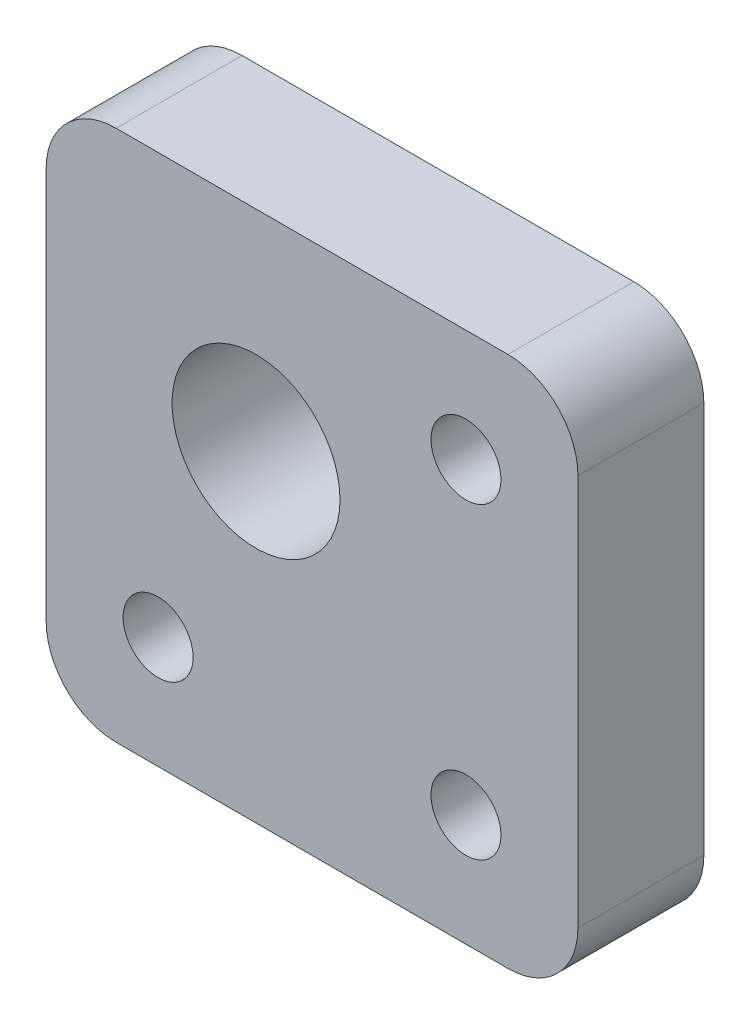
from build123d import *

# Parameters (mm, degrees)
SKETCH_1_W      = 38
SKETCH_1_H      = 38
SKETCH_1_R      = 2.5
SKETCH_1_R_2    = 6
EXTRUDE_1_DEPTH = 9
FILLET_1_R      = 5


with BuildPart() as part:
    # 草图1 → 凸台-拉伸1 (new body)
    with BuildSketch(Plane.XY):
        with Locations((-2.169799589, 0.839779006)):
            Rectangle(SKETCH_1_W, SKETCH_1_H)
        with Locations((8.830200411, 11.839779006)):
            Circle(SKETCH_1_R, mode=Mode.SUBTRACT)
        with Locations((8.830200411, -10.160220994)):
            Circle(SKETCH_1_R, mode=Mode.SUBTRACT)
        with Locations((-13.169799589, -10.160220994)):
            Circle(SKETCH_1_R, mode=Mode.SUBTRACT)
        with Locations((-6.169799589, 4.839779006)):
            Circle(SKETCH_1_R_2, mode=Mode.SUBTRACT)
    extrude(amount=EXTRUDE_1_DEPTH)

    # 圆角1
    fillet_1_edges = [part.edges().sort_by_distance(p)[0] for p in [
        (-21.169799589, 19.839779006, 4.5),
        (16.830200411, 19.839779006, 4.5),
        (16.830200411, -18.160220994, 4.5),
        (-21.169799589, -18.160220994, 4.5),
    ]]
    fillet(fillet_1_edges, radius=FILLET_1_R)


solid = part.part
